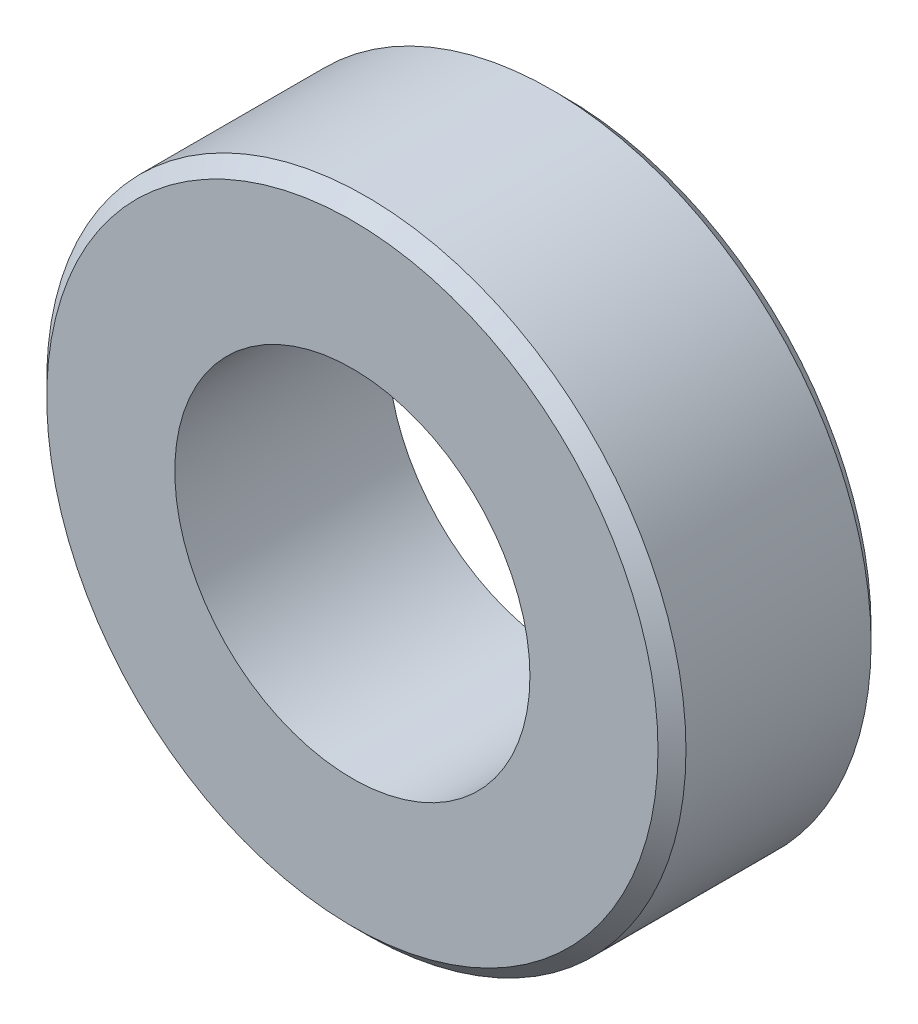
from build123d import *

# Parameters (mm, degrees)
SKETCH1_R           = 11.43
SKETCH1_R_2         = 6.35
BOSS_EXTRUDE1_DEPTH = 7.62
CHAMFER1_SIZE       = 0.5


with BuildPart() as part:
    # Sketch1 → Boss-Extrude1 (new body)
    with BuildSketch(Plane.XY):
        Circle(SKETCH1_R)
        Circle(SKETCH1_R_2, mode=Mode.SUBTRACT)
    extrude(amount=BOSS_EXTRUDE1_DEPTH)

    # Chamfer1
    chamfer1_edges = [part.edges().sort_by_distance(p)[0] for p in [
        (-11.43, 0, 0),
        (-11.43, 0, 7.62),
    ]]
    chamfer(chamfer1_edges, length=CHAMFER1_SIZE)


solid = part.part
